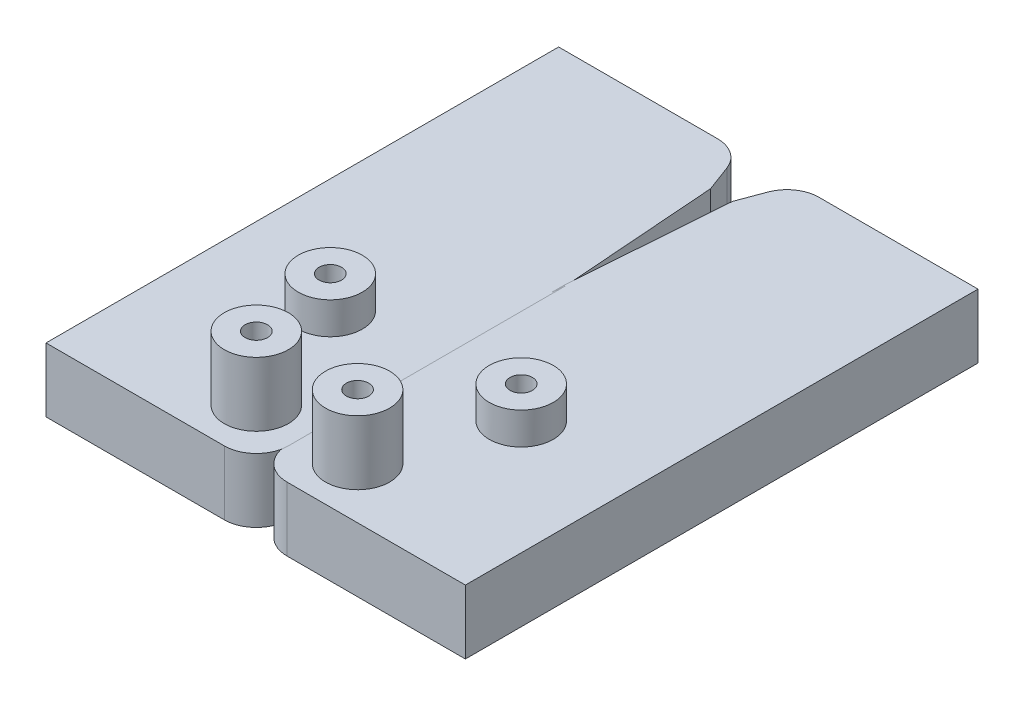
from build123d import *

# Parameters (mm, degrees)
BOSS_EXTRUDE1_DEPTH = 10
SKETCH2_R           = 5
BOSS_EXTRUDE2_DEPTH = 10
SKETCH3_R           = 5
BOSS_EXTRUDE3_DEPTH = 5
SKETCH4_R           = 1.75
CUT_EXTRUDE1_DEPTH  = 10
SKETCH5_R           = 1.75
CUT_EXTRUDE2_DEPTH  = 10


with BuildPart() as part:
    # Sketch1 → Boss-Extrude1 (new body)
    with BuildSketch(Plane(origin=(0, 0, 0), x_dir=(1, 0, 0), z_dir=(0, 1, 0))):
        with BuildLine():
            Line((-32.724156306, 27.617451147), (-7.907589804, 27.617451147))
            ThreePointArc((-7.907589804, 27.617451147), (-5.055118604, 26.723959158), (-3.222111469, 24.362814367))
            Line((-3.222111469, 24.362814367), (-1.713922655, 20.314037625))
            Line((-1.713922655, 20.314037625), (0.1, -4.04973357))
            Line((0.1, -4.04973357), (0.1, -47.382548853))
            ThreePointArc((0.1, -47.382548853), (-1.364466094, -50.918082759), (-4.9, -52.382548853))
            Line((-4.9, -52.382548853), (-32.724156306, -52.382548853))
            Line((-32.724156306, -52.382548853), (-32.724156306, 27.617451147))
        make_face()
    extrude(amount=BOSS_EXTRUDE1_DEPTH)

    # Sketch2 → Boss-Extrude2 (add)
    with BuildSketch(Plane(origin=(0, 10, 0), x_dir=(1, 0, 0), z_dir=(0, 1, 0))):
        with Locations((-7.9, -44.382548853)):
            Circle(SKETCH2_R)
    extrude(amount=BOSS_EXTRUDE2_DEPTH)

    # Sketch3 → Boss-Extrude3 (add)
    with BuildSketch(Plane(origin=(0, 10, 0), x_dir=(1, 0, 0), z_dir=(0, 1, 0))):
        with Locations((-14.9, -25.840736372)):
            Circle(SKETCH3_R)
    extrude(amount=BOSS_EXTRUDE3_DEPTH)

    # Sketch4 → Cut-Extrude1 (cut)
    with BuildSketch(Plane(origin=(0, 20, 0), x_dir=(1, 0, 0), z_dir=(0, 1, 0))):
        with Locations((-7.9, -44.382548853)):
            Circle(SKETCH4_R)
    extrude(amount=-CUT_EXTRUDE1_DEPTH, mode=Mode.SUBTRACT)

    # Sketch5 → Cut-Extrude2 (cut)
    with BuildSketch(Plane(origin=(0, 15, 0), x_dir=(1, 0, 0), z_dir=(0, 1, 0))):
        with Locations((-14.9, -25.840736372)):
            Circle(SKETCH5_R)
    extrude(amount=-CUT_EXTRUDE2_DEPTH, mode=Mode.SUBTRACT)


with BuildPart() as body_2:
    # Mirror4: mirrored copy
    add(part.part.mirror(Plane(origin=(0, 0, 0), x_dir=(0, 0, 1), z_dir=(1, 0, 0))))


solid = Compound([part.part, body_2.part])
